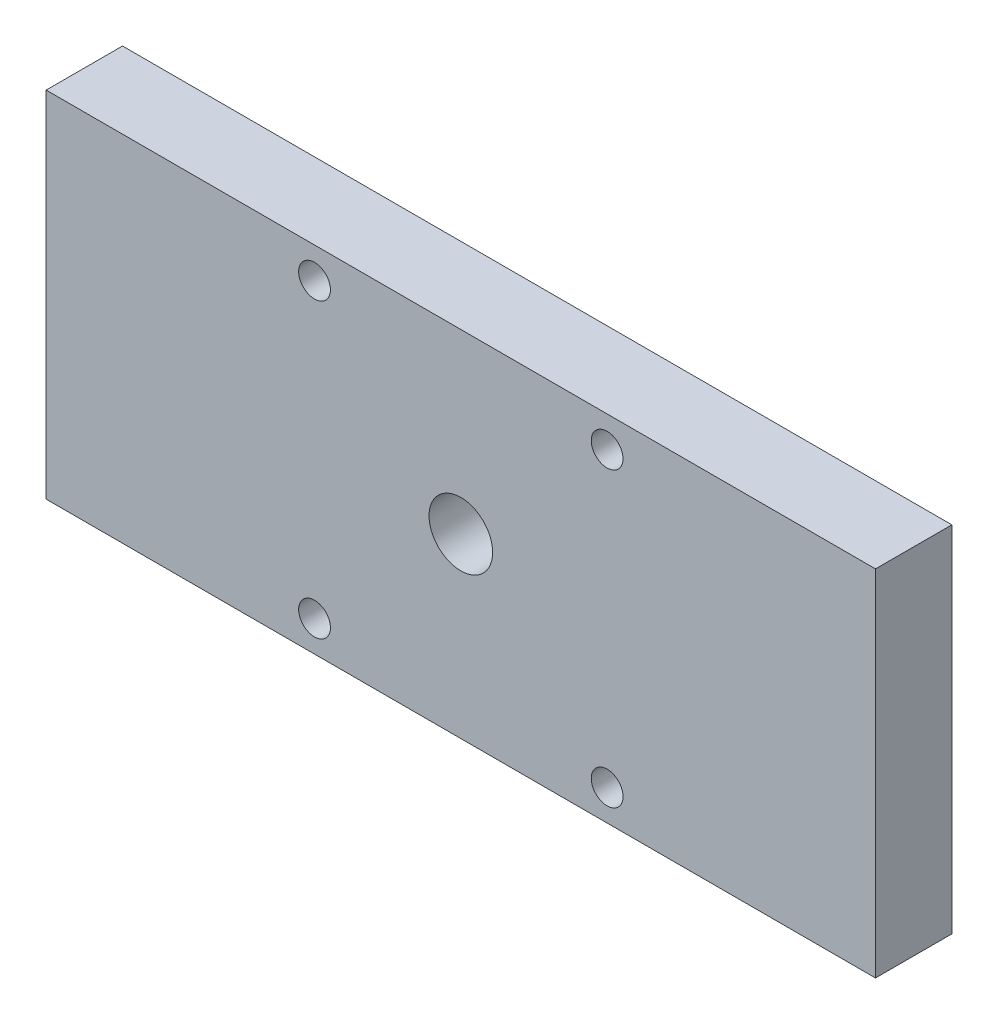
from build123d import *

# Parameters (mm, degrees)
ESQUISSE1_W             = 65.19
ESQUISSE1_H             = 27.85
BOSS_EXTRU_1_DEPTH      = 6
ESQUISSE2_R             = 2.5
ESQUISSE2_R_2           = 1.25
ENL_V_MAT_EXTRU_1_DEPTH = 6


with BuildPart() as part:
    # Esquisse1 → Boss.-Extru.1 (new body)
    with BuildSketch(Plane.XY):
        with Locations((9.86683908, -0.560201149)):
            Rectangle(ESQUISSE1_W, ESQUISSE1_H)
    extrude(amount=BOSS_EXTRU_1_DEPTH)

    # Esquisse2 → Enlèv. mat.-Extru.1 (cut)
    with BuildSketch(Plane.XY.offset(6)):
        with Locations((9.86683908, -0.565201149)):
            Circle(ESQUISSE2_R)
        with Locations((-1.63316092, 10.934798851)):
            Circle(ESQUISSE2_R_2)
        with Locations((21.36683908, 10.934798851)):
            Circle(ESQUISSE2_R_2)
        with Locations((21.36683908, -12.065201149)):
            Circle(ESQUISSE2_R_2)
        with Locations((-1.63316092, -12.065201149)):
            Circle(ESQUISSE2_R_2)
    extrude(amount=-ENL_V_MAT_EXTRU_1_DEPTH, mode=Mode.SUBTRACT)


solid = part.part
